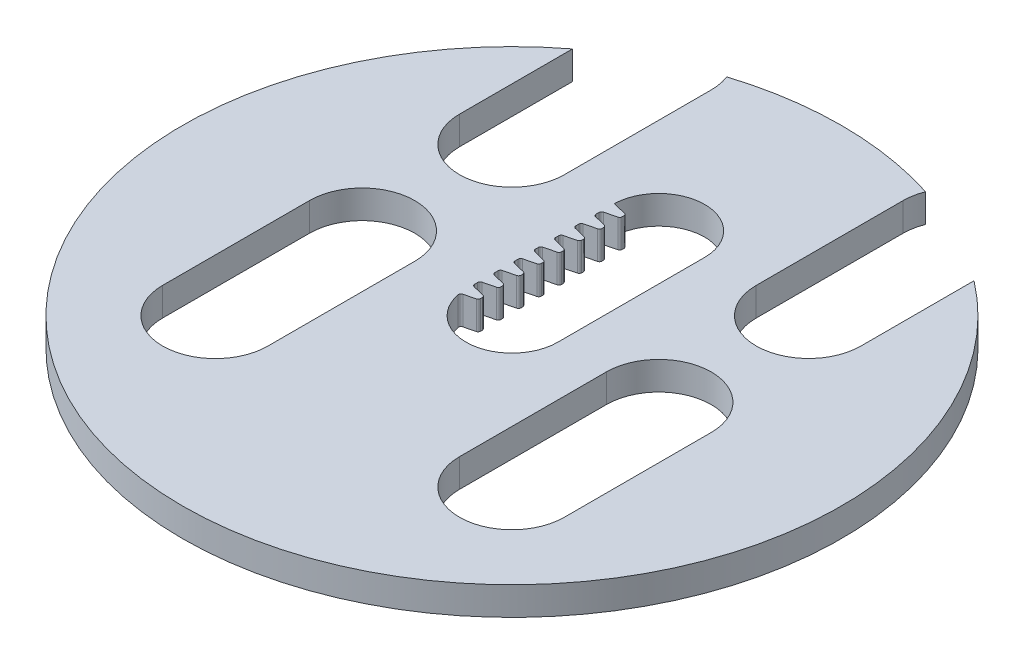
from build123d import *

# Parameters (mm, degrees)
BOSS_EXTRUDE1_DEPTH      = 3.175
BOSS_EXTRUDE1_DEPTH_BACK = 0.254
BOSS_EXTRUDE2_DEPTH      = 3.429
LPATTERN1_COUNT          = 8
LPATTERN1_PITCH          = 2.45
FILLET1_R                = 0.3


with BuildPart() as part:
    # Sketch3 → Boss-Extrude1 (new body, two sides)
    with BuildSketch(Plane.XZ) as boss_extrude1_sk:
        with BuildLine():
            ThreePointArc((39.9034, 0), (-17.63815803, 35.793528925), (-24.310512242, -31.643013859))
            Line((-24.310512242, -31.643013859), (-24.310512242, -17.960512242))
            ThreePointArc((-24.310512242, -17.960512242), (-17.960512242, -11.610512242), (-11.610512242, -17.960512242))
            Line((-11.610512242, -17.960512242), (-11.610512242, -35.740512242))
            ThreePointArc((-11.610512242, -35.740512242), (-11.71946636, -36.911770666), (-12.042589815, -38.042835884))
            ThreePointArc((-12.042589815, -38.042835884), (0, -39.9034), (12.042589815, -38.042835884))
            ThreePointArc((12.042589815, -38.042835884), (11.71946636, -36.911770666), (11.610512242, -35.740512242))
            Line((11.610512242, -35.740512242), (11.610512242, -17.960512242))
            ThreePointArc((11.610512242, -17.960512242), (17.960512242, -11.610512242), (24.310512242, -17.960512242))
            Line((24.310512242, -17.960512242), (24.310512242, -31.643013859))
            ThreePointArc((24.310512242, -31.643013859), (35.793528925, -17.63815803), (39.9034, 0))
        make_face()
        with BuildLine():
            ThreePointArc((-5.55625, 0), (0, 5.55625), (5.55625, 0))
            Line((5.55625, 0), (5.55625, -17.78))
            ThreePointArc((5.55625, -17.78), (0, -23.33625), (-5.55625, -17.78))
            Line((-5.55625, -17.78), (-5.55625, 0))
        make_face(mode=Mode.SUBTRACT)
        with BuildLine():
            ThreePointArc((-11.590512242, 0.180512242), (-17.960512242, -6.189487758), (-24.330512242, 0.180512242))
            Line((-24.330512242, 0.180512242), (-24.330512242, 17.960512242))
            ThreePointArc((-24.330512242, 17.960512242), (-17.960512242, 24.330512242), (-11.590512242, 17.960512242))
            Line((-11.590512242, 17.960512242), (-11.590512242, 0.180512242))
        make_face(mode=Mode.SUBTRACT)
        with BuildLine():
            ThreePointArc((24.310512242, 0.180512242), (17.960512242, -6.169487758), (11.610512242, 0.180512242))
            Line((11.610512242, 0.180512242), (11.610512242, 17.960512242))
            ThreePointArc((11.610512242, 17.960512242), (17.960512242, 24.310512242), (24.310512242, 17.960512242))
            Line((24.310512242, 17.960512242), (24.310512242, 0.180512242))
        make_face(mode=Mode.SUBTRACT)
    extrude(amount=BOSS_EXTRUDE1_DEPTH)
    extrude(boss_extrude1_sk.sketch, amount=-BOSS_EXTRUDE1_DEPTH_BACK)

    # Sketch4 → Boss-Extrude2 (add)
    with BuildSketch(Plane(origin=(0, 0.254, 0), x_dir=(1, 0, 0), z_dir=(0, 1, 0))):
        Polygon((-5.55625, -0.803750085), (-3.69625, -0.34), (-3.69625, 0.34), (-5.55625, 0.803750085), align=None)
    boss_extrude2 = extrude(amount=-BOSS_EXTRUDE2_DEPTH)

    # LPattern1: Boss-Extrude2 ×8
    with Locations(*[(0, 0, -i * LPATTERN1_PITCH) for i in range(1, LPATTERN1_COUNT)]):
        add(boss_extrude2)

    # Fillet1
    fillet1_edges = [part.edges().sort_by_distance(p)[0] for p in [
        (-3.69625, -1.4605, 0.34),
        (-5.55625, -1.4605, -0.803750085),
        (-3.69625, -1.4605, -0.34),
        (-5.499846219, -1.4605, 0.789687043),
        (-5.55625, -1.4605, -1.646249915),
        (-5.55625, -1.4605, -3.253750085),
        (-3.69625, -1.4605, -2.79),
        (-3.69625, -1.4605, -2.11),
        (-5.55625, -1.4605, -4.096249915),
        (-5.55625, -1.4605, -5.703750085),
        (-3.69625, -1.4605, -5.24),
        (-3.69625, -1.4605, -4.56),
        (-5.55625, -1.4605, -6.546249915),
        (-5.55625, -1.4605, -8.153750085),
        (-3.69625, -1.4605, -7.69),
        (-3.69625, -1.4605, -7.01),
        (-5.55625, -1.4605, -8.996249915),
        (-5.55625, -1.4605, -10.603750085),
        (-3.69625, -1.4605, -10.14),
        (-3.69625, -1.4605, -9.46),
        (-5.55625, -1.4605, -11.446249915),
        (-5.55625, -1.4605, -13.053750085),
        (-3.69625, -1.4605, -12.59),
        (-3.69625, -1.4605, -11.91),
        (-5.55625, -1.4605, -13.896249915),
        (-5.55625, -1.4605, -15.503750085),
        (-3.69625, -1.4605, -15.04),
        (-3.69625, -1.4605, -14.36),
        (-5.55625, -1.4605, -16.346249915),
        (-3.69625, -1.4605, -17.49),
        (-3.69625, -1.4605, -16.81),
    ]]
    fillet(fillet1_edges, radius=FILLET1_R)


solid = part.part
